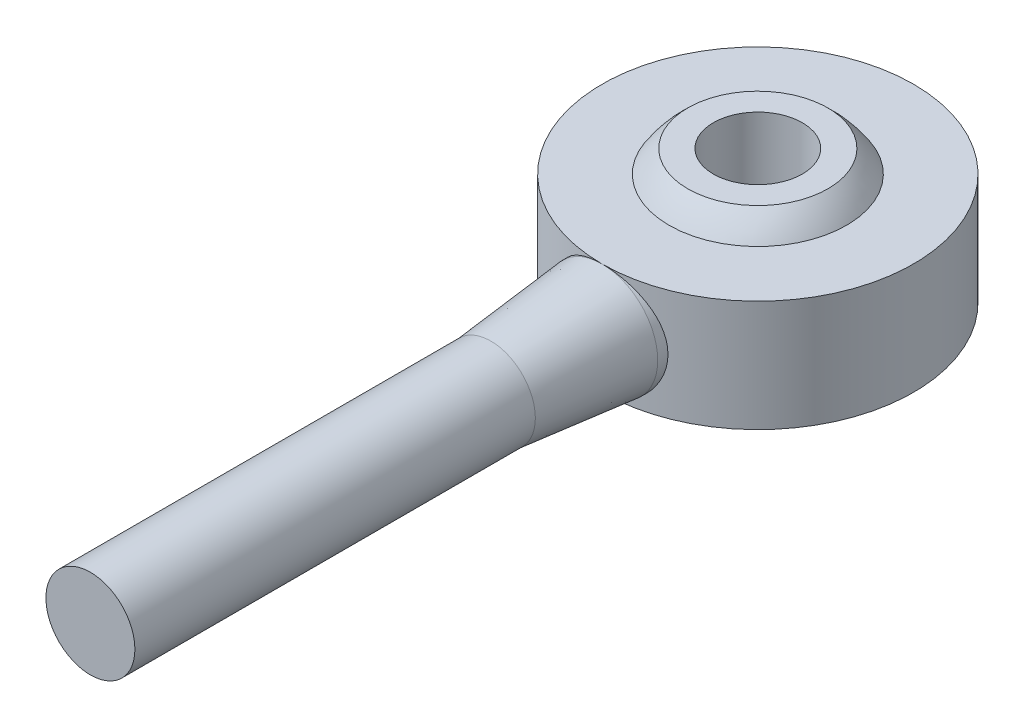
from build123d import *

# Parameters (mm, degrees)
SKETCH1_R           = 7
SKETCH1_R_2         = 3.25
BOSS_EXTRUDE1_DEPTH = 2.5


with BuildPart() as part:
    # Sketch1 → Boss-Extrude1 (new body, symmetric)
    with BuildSketch(Plane(origin=(0, 0, 0), x_dir=(1, 0, 0), z_dir=(0, 1, 0))):
        Circle(SKETCH1_R)
        Circle(SKETCH1_R_2, mode=Mode.SUBTRACT)
    extrude(amount=BOSS_EXTRUDE1_DEPTH, both=True)

    # Sketch2 → Revolve1 (revolve)
    with BuildSketch(Plane(origin=(0, 0, 0), x_dir=(0, 0, -1), z_dir=(1, 0, 0))):
        with BuildLine():
            Line((-3.15, 3.5), (-2, 3.5))
            Line((-2, 3.5), (-2, -3.5))
            Line((-2, -3.5), (-3.15, -3.5))
            ThreePointArc((-3.15, -3.5), (-4.708768416, 0), (-3.15, 3.5))
        make_face()
    revolve(axis=Axis((0, 6, 0), (0, -1, 0)))

    # Sketch3 → Revolve2 (revolve)
    with BuildSketch(Plane(origin=(0, 0, 0), x_dir=(0, 0, -1), z_dir=(1, 0, 0))):
        Polygon((-12, 2), (-7, 2.5), (-5, 2.5), (-5, 0), (-30, 0), (-30, 2), align=None)
    revolve(axis=Axis((0, 0, 30), (0, 0, -1)))


solid = part.part
